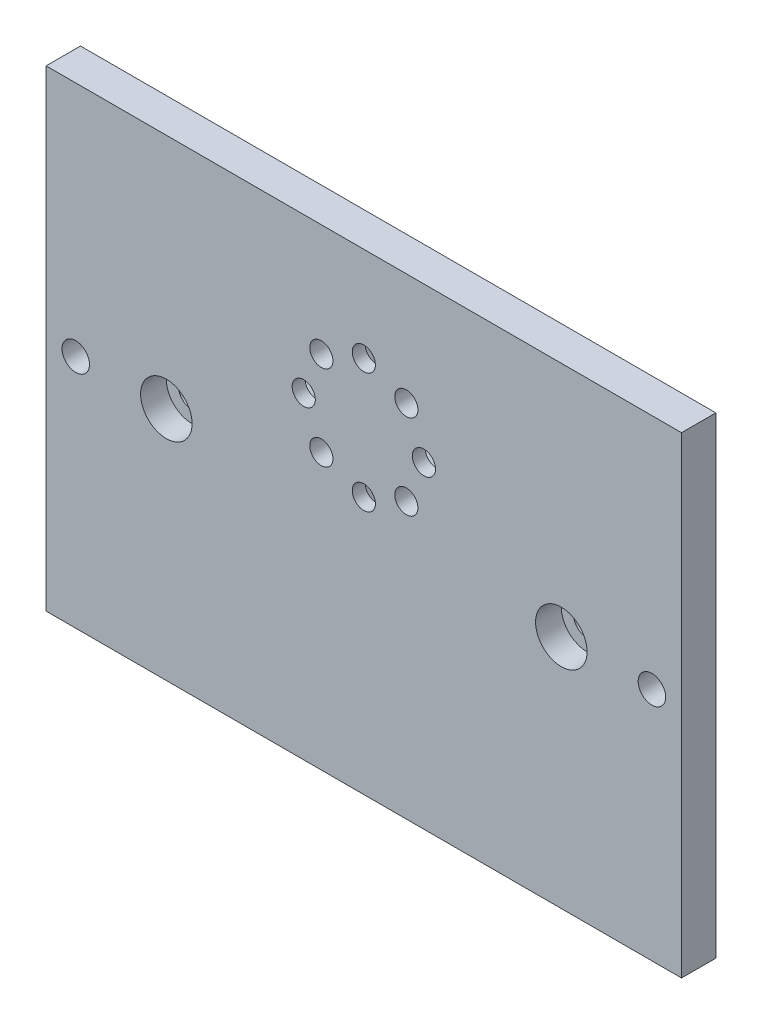
from build123d import *

# Parameters (mm, degrees)
SKETCH_1_W          = 74
SKETCH_1_H          = 55
EXTRUDE_1_DEPTH     = 4
SKETCH_2_R          = 1.6
CUT_EXTRUDE_1_DEPTH = 47.273642606
SKETCH_2_3_R        = 1.35
CUT_EXTRUDE_2_DEPTH = 47.273642606
CUT_EXTRUDE_3_DEPTH = 2.5
SKETCH_5_R          = 3
CUT_EXTRUDE_4_DEPTH = 3


with BuildPart() as part:
    # 草圖1 → 填料-伸長1 (new body)
    with BuildSketch(Plane.XY):
        Rectangle(SKETCH_1_W, SKETCH_1_H)
    extrude(amount=EXTRUDE_1_DEPTH)

    # 草圖2 → 除料-伸長1 (cut, through all)
    with BuildSketch(Plane.XY.offset(4)):
        with Locations((-33.55, -0.1)):
            Circle(SKETCH_2_R)
        with Locations((33.55, -0.1)):
            Circle(SKETCH_2_R)
        with Locations((-23, -0.1)):
            Circle(SKETCH_2_R)
        with Locations((23, -0.1)):
            Circle(SKETCH_2_R)
    extrude(amount=-CUT_EXTRUDE_1_DEPTH, mode=Mode.SUBTRACT)

    # 草圖2<3> → 除料-伸長2 (cut, through all)
    with BuildSketch(Plane.XY.offset(4)):
        with Locations((0, 2.5)):
            Circle(SKETCH_2_3_R)
        with Locations((-4.949747468, 4.550252532)):
            Circle(SKETCH_2_3_R)
        with Locations((-7, 9.5)):
            Circle(SKETCH_2_3_R)
        with Locations((-4.949747468, 14.449747468)):
            Circle(SKETCH_2_3_R)
        with Locations((0, 16.5)):
            Circle(SKETCH_2_3_R)
        with Locations((4.949747468, 14.449747468)):
            Circle(SKETCH_2_3_R)
        with Locations((7, 9.5)):
            Circle(SKETCH_2_3_R)
        with Locations((4.949747468, 4.550252532)):
            Circle(SKETCH_2_3_R)
    extrude(amount=-CUT_EXTRUDE_2_DEPTH, mode=Mode.SUBTRACT)

    # 草圖3 → 除料-伸長3 (cut)
    with BuildSketch(Plane(origin=(0, 0, 0), x_dir=(-1, 0, 0), z_dir=(0, 0, -1))):
        Polygon((-1.58771324, 19.25), (1.58771324, 19.25), (3.175426481, 16.5), (1.58771324, 13.75), (-1.58771324, 13.75), (-3.175426481, 16.5), align=None)
        Polygon((9.75, 7.91228676), (7, 6.324573519), (4.25, 7.91228676), (4.25, 11.08771324), (7, 12.675426481), (9.75, 11.08771324), align=None)
        Polygon((-1.58771324, -0.25), (-3.175426481, 2.5), (-1.58771324, 5.25), (1.58771324, 5.25), (3.175426481, 2.5), (1.58771324, -0.25), align=None)
        Polygon((-9.75, 11.08771324), (-7, 12.675426481), (-4.25, 11.08771324), (-4.25, 7.91228676), (-7, 6.324573519), (-9.75, 7.91228676), align=None)
    extrude(amount=-CUT_EXTRUDE_3_DEPTH, mode=Mode.SUBTRACT)

    # 草圖5 → 除料-伸長4 (cut)
    with BuildSketch(Plane.XY.offset(4)):
        with Locations((23, -0.1)):
            Circle(SKETCH_5_R)
        with Locations((-23, -0.1)):
            Circle(SKETCH_5_R)
    extrude(amount=-CUT_EXTRUDE_4_DEPTH, mode=Mode.SUBTRACT)


solid = part.part
